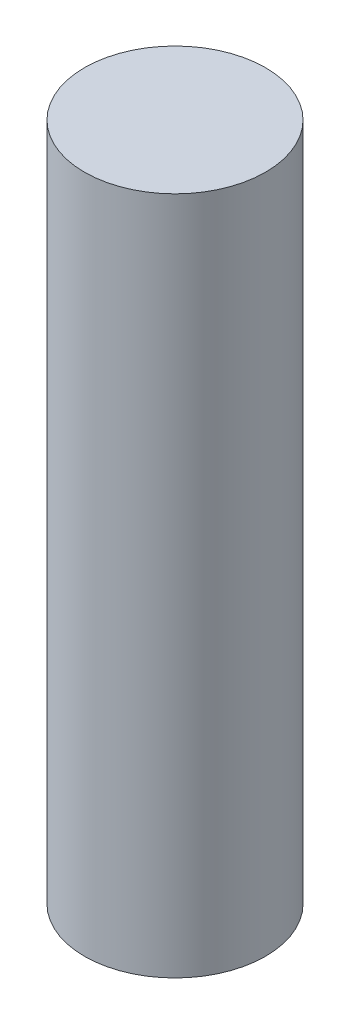
from build123d import *

# Parameters (mm, degrees)
SKETCH1_R           = 60
BOSS_EXTRUDE1_DEPTH = 450


with BuildPart() as part:
    # Sketch1 → Boss-Extrude1 (new body)
    with BuildSketch(Plane(origin=(0, 0, 0), x_dir=(1, 0, 0), z_dir=(0, 1, 0))):
        Circle(SKETCH1_R)
    extrude(amount=BOSS_EXTRUDE1_DEPTH)


solid = part.part
